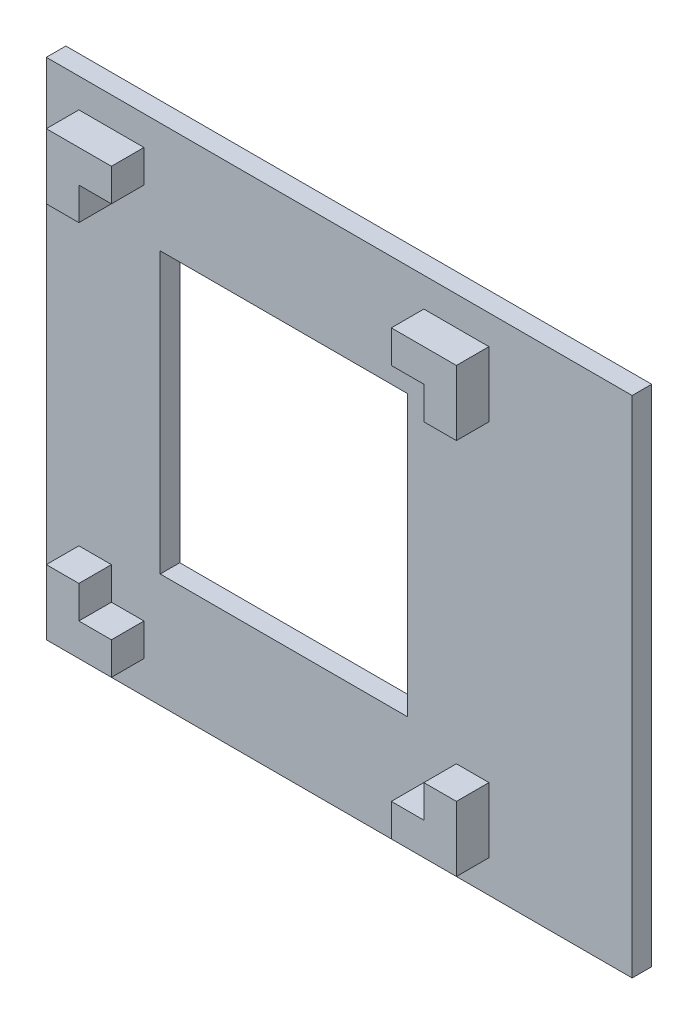
from build123d import *

# Parameters (mm, degrees)
BOSS_EXTRUDE2_DEPTH   = 8
BOSS_EXTRUDE2_2_DEPTH = 8
BOSS_EXTRUDE2_3_DEPTH = 8
BOSS_EXTRUDE2_4_DEPTH = 8
SKETCH1_4_W           = 90
SKETCH1_4_H           = 77.5
BOSS_EXTRUDE3_DEPTH   = 3
SKETCH4_W             = 38
SKETCH4_H             = 43
CUT_EXTRUDE2_DEPTH    = 3


with BuildPart() as part:
    # Sketch1 → Boss-Extrude2 (new body)
    with BuildSketch(Plane.XY):
        Polygon((15, 5), (15, 10), (10, 10), (10, 15), (5, 15), (5, 5), align=None)
    extrude(amount=BOSS_EXTRUDE2_DEPTH)



with BuildPart() as body_2:
    # Sketch1 → Boss-Extrude2 2 (new body)
    with BuildSketch(Plane.XY):
        Polygon((58, 73), (58, 68), (63, 68), (63, 63), (68, 63), (68, 73), align=None)
    extrude(amount=BOSS_EXTRUDE2_2_DEPTH)


with BuildPart() as body_3:
    # Sketch1 → Boss-Extrude2 3 (new body)
    with BuildSketch(Plane.XY):
        Polygon((63, 10), (58, 10), (58, 5), (68, 5), (68, 15), (63, 15), align=None)
    extrude(amount=BOSS_EXTRUDE2_3_DEPTH)


with BuildPart() as body_4:
    # Sketch1 → Boss-Extrude2 4 (new body)
    with BuildSketch(Plane.XY):
        Polygon((10, 68), (15, 68), (15, 73), (5, 73), (5, 63), (10, 63), align=None)
    extrude(amount=BOSS_EXTRUDE2_4_DEPTH)


with BuildPart() as part_1:
    add(part.part)

    add(body_2.part)  # Boss-Extrude3 merges body 2

    add(body_3.part)  # Boss-Extrude3 merges body 3

    add(body_4.part)  # Boss-Extrude3 merges body 4
    # Sketch1_4 → Boss-Extrude3 (add)
    with BuildSketch(Plane.XY):
        with Locations((45, 38.75)):
            Rectangle(SKETCH1_4_W, SKETCH1_4_H)
        Polygon((10, 10), (15, 10), (15, 5), (5, 5), (5, 15), (10, 15), align=None, mode=Mode.SUBTRACT)
        Polygon((5, 63), (5, 73), (15, 73), (15, 68), (10, 68), (10, 63), align=None, mode=Mode.SUBTRACT)
        Polygon((58, 68), (58, 73), (68, 73), (68, 63), (63, 63), (63, 68), align=None, mode=Mode.SUBTRACT)
        Polygon((58, 5), (58, 10), (63, 10), (63, 15), (68, 15), (68, 5), align=None, mode=Mode.SUBTRACT)
    extrude(amount=BOSS_EXTRUDE3_DEPTH)

    # Sketch4 → Cut-Extrude2 (cut)
    with BuildSketch(Plane.XY.offset(3)):
        with Locations((36.5, 39)):
            Rectangle(SKETCH4_W, SKETCH4_H)
    extrude(amount=-CUT_EXTRUDE2_DEPTH, mode=Mode.SUBTRACT)


solid = part_1.part
